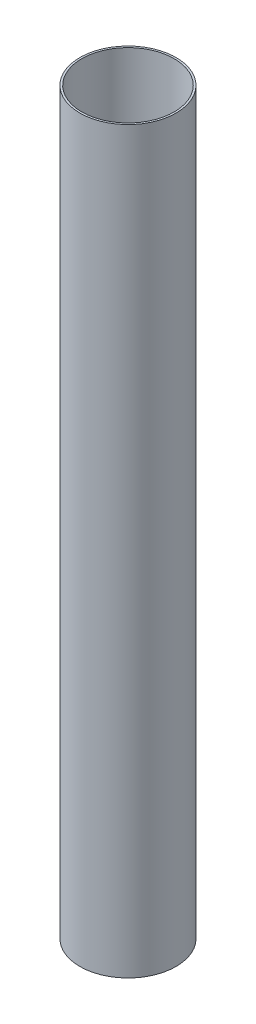
from build123d import *

# Parameters (mm, degrees)
SKETCH2_R           = 79.375
SKETCH2_R_2         = 76.2
BOSS_EXTRUDE1_DEPTH = 1219.2


with BuildPart() as part:
    # Sketch2 → Boss-Extrude1 (new body)
    with BuildSketch(Plane(origin=(0, 0, 0), x_dir=(1, 0, 0), z_dir=(0, 1, 0))):
        Circle(SKETCH2_R)
        Circle(SKETCH2_R_2, mode=Mode.SUBTRACT)
    extrude(amount=BOSS_EXTRUDE1_DEPTH)


solid = part.part
